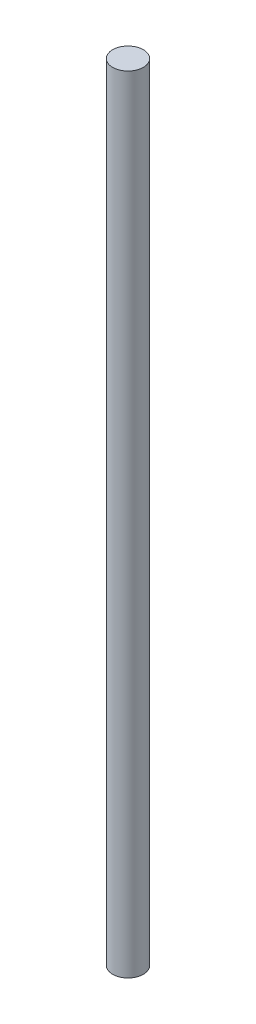
from build123d import *

# Parameters (mm, degrees)
SKETCH1_R           = 3.96875
BOSS_EXTRUDE1_DEPTH = 203.2


with BuildPart() as part:
    # Sketch1 → Boss-Extrude1 (new body)
    with BuildSketch(Plane(origin=(0, 0, 0), x_dir=(1, 0, 0), z_dir=(0, 1, 0))):
        Circle(SKETCH1_R)
    extrude(amount=BOSS_EXTRUDE1_DEPTH)


solid = part.part
